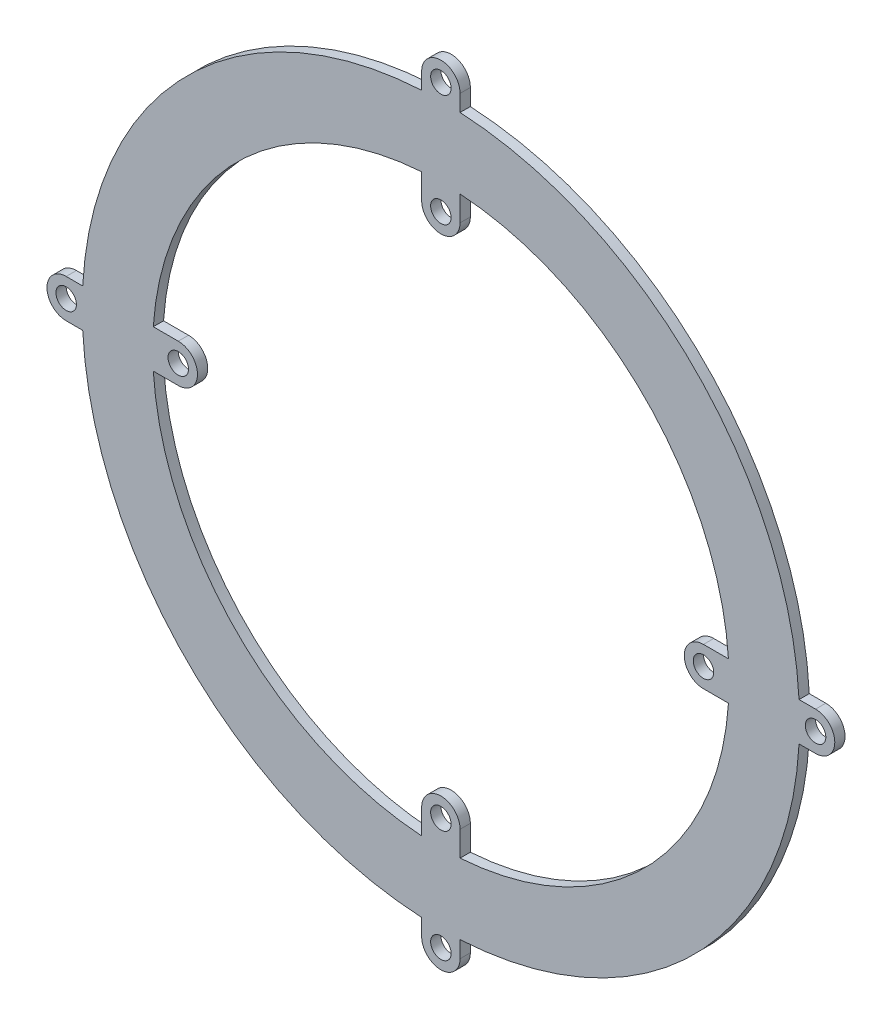
from build123d import *

# Parameters (mm, degrees)
SKETCH1_R           = 1.6
BOSS_EXTRUDE1_DEPTH = 1.6


with BuildPart() as part:
    # Sketch1 → Boss-Extrude1 (new body)
    with BuildSketch(Plane.XY):
        with BuildLine():
            Line((-58.5, -3), (-55.91958512, -3))
            ThreePointArc((-55.91958512, -3), (-39.597979746, -39.597979746), (-3, -55.91958512))
            Line((-3, -55.91958512), (-3, -58.5))
            ThreePointArc((-3, -58.5), (0, -61.5), (3, -58.5))
            Line((3, -58.5), (3, -55.91958512))
            ThreePointArc((3, -55.91958512), (39.597979746, -39.597979746), (55.91958512, -3))
            Line((55.91958512, -3), (58.5, -3))
            ThreePointArc((58.5, -3), (61.5, 0), (58.5, 3))
            Line((58.5, 3), (55.91958512, 3))
            ThreePointArc((55.91958512, 3), (39.597979746, 39.597979746), (3, 55.91958512))
            Line((3, 55.91958512), (3, 58.5))
            ThreePointArc((3, 58.5), (0, 61.5), (-3, 58.5))
            Line((-3, 58.5), (-3, 55.91958512))
            ThreePointArc((-3, 55.91958512), (-39.597979746, 39.597979746), (-55.91958512, 3))
            Line((-55.91958512, 3), (-58.5, 3))
            ThreePointArc((-58.5, 3), (-61.5, 0), (-58.5, -3))
        make_face()
        with Locations((-41, 0)):
            Circle(SKETCH1_R, mode=Mode.SUBTRACT)
        with Locations((0, -41)):
            Circle(SKETCH1_R, mode=Mode.SUBTRACT)
        with Locations((41, 0)):
            Circle(SKETCH1_R, mode=Mode.SUBTRACT)
        with Locations((0, 41)):
            Circle(SKETCH1_R, mode=Mode.SUBTRACT)
        with Locations((-58.5, 0)):
            Circle(SKETCH1_R, mode=Mode.SUBTRACT)
        with Locations((0, 58.5)):
            Circle(SKETCH1_R, mode=Mode.SUBTRACT)
        with Locations((58.5, 0)):
            Circle(SKETCH1_R, mode=Mode.SUBTRACT)
        with Locations((0, -58.5)):
            Circle(SKETCH1_R, mode=Mode.SUBTRACT)
        with BuildLine():
            ThreePointArc((44.899888641, 3), (31.819805153, 31.819805153), (3, 44.899888641))
            Line((3, 44.899888641), (3, 41))
            ThreePointArc((3, 41), (0, 38), (-3, 41))
            Line((-3, 41), (-3, 44.899888641))
            ThreePointArc((-3, 44.899888641), (-31.819805153, 31.819805153), (-44.899888641, 3))
            Line((-44.899888641, 3), (-41, 3))
            ThreePointArc((-41, 3), (-38, 0), (-41, -3))
            Line((-41, -3), (-44.899888641, -3))
            ThreePointArc((-44.899888641, -3), (-31.819805153, -31.819805153), (-3, -44.899888641))
            Line((-3, -44.899888641), (-3, -41))
            ThreePointArc((-3, -41), (0, -38), (3, -41))
            Line((3, -41), (3, -44.899888641))
            ThreePointArc((3, -44.899888641), (31.819805153, -31.819805153), (44.899888641, -3))
            Line((44.899888641, -3), (41, -3))
            ThreePointArc((41, -3), (38, 0), (41, 3))
            Line((41, 3), (44.899888641, 3))
        make_face(mode=Mode.SUBTRACT)
    extrude(amount=BOSS_EXTRUDE1_DEPTH)


solid = part.part
